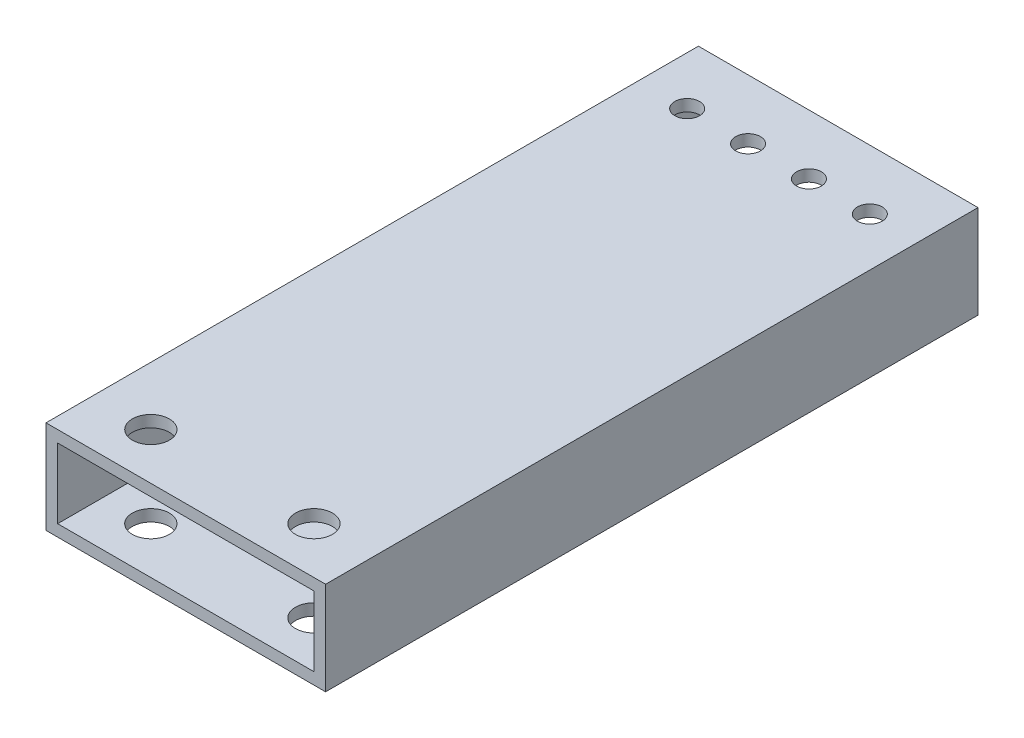
from build123d import *

# Parameters (mm, degrees)
SKETCH1_W           = 76.2
SKETCH1_H           = 25.4
SKETCH1_W_2         = 69.85
SKETCH1_H_2         = 19.05
BOSS_EXTRUDE1_DEPTH = 177.8
SKETCH4_R           = 3.3782
CUT_EXTRUDE1_DEPTH  = 26.4
SKETCH5_R           = 5.0419
CUT_EXTRUDE2_DEPTH  = 26.4


with BuildPart() as part:
    # Sketch1 → Boss-Extrude1 (new body)
    with BuildSketch(Plane.XY):
        with Locations((38.1, 12.7)):
            Rectangle(SKETCH1_W, SKETCH1_H)
        with Locations((38.1, 12.7)):
            Rectangle(SKETCH1_W_2, SKETCH1_H_2, mode=Mode.SUBTRACT)
    extrude(amount=BOSS_EXTRUDE1_DEPTH)

    # Sketch4 → Cut-Extrude1 (cut, through all)
    with BuildSketch(Plane(origin=(0, 25.4, 0), x_dir=(1, 0, 0), z_dir=(0, 1, 0))):
        with Locations((13.21308, -16.2687)):
            Circle(SKETCH4_R)
        with Locations((29.80436, -16.2687)):
            Circle(SKETCH4_R)
        with Locations((46.39564, -16.2687)):
            Circle(SKETCH4_R)
        with Locations((62.98692, -16.2687)):
            Circle(SKETCH4_R)
    extrude(amount=-CUT_EXTRUDE1_DEPTH, mode=Mode.SUBTRACT)

    # Sketch5 → Cut-Extrude2 (cut, through all)
    with BuildSketch(Plane.XZ):
        with Locations((60.325, 165.1)):
            Circle(SKETCH5_R)
        with Locations((15.875, 165.1)):
            Circle(SKETCH5_R)
    extrude(amount=-CUT_EXTRUDE2_DEPTH, mode=Mode.SUBTRACT)


solid = part.part
